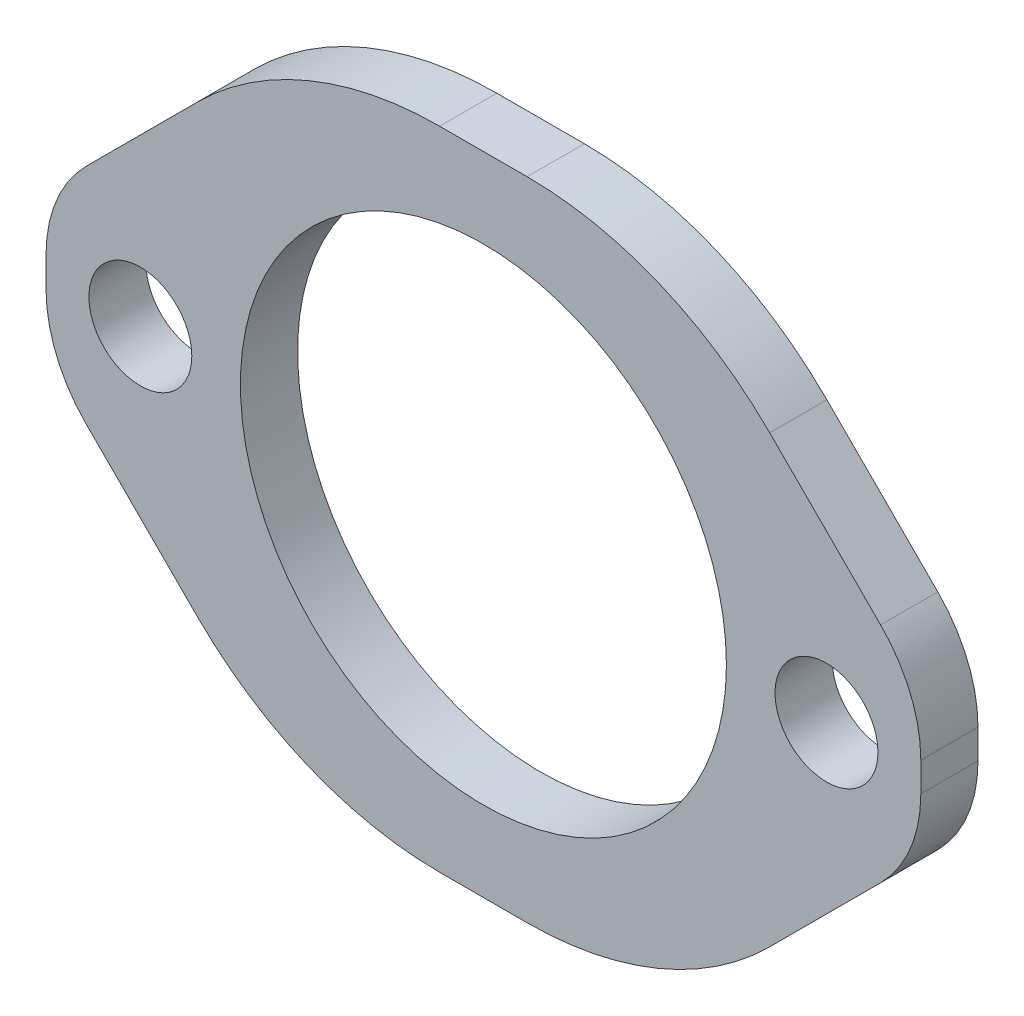
from build123d import *

# Parameters (mm, degrees)
ESQUISSE1_W        = 76.5
ESQUISSE1_H        = 56.5
ESQUISSE1_R        = 21.25
ESQUISSE1_R_2      = 4.5
BOSS_EXTRU_1_DEPTH = 5
CHANFREIN1_SIZE    = 22
CHANFREIN2_SIZE    = 22
CHANFREIN3_SIZE    = 22
CHANFREIN4_SIZE    = 22
CONG_2_R           = 30
CONG_3_R           = 30
CONG_4_R           = 30
CONG_5_R           = 30
CONG_6_R           = 12
CONG_7_R           = 12
CONG_8_R           = 12
CONG_9_R           = 12


with BuildPart() as part:
    # Esquisse1 → Boss.-Extru.1 (new body)
    with BuildSketch(Plane.XY):
        Rectangle(ESQUISSE1_W, ESQUISSE1_H)
        Circle(ESQUISSE1_R, mode=Mode.SUBTRACT)
        with Locations((30, 0)):
            Circle(ESQUISSE1_R_2, mode=Mode.SUBTRACT)
        with Locations((-30, 0)):
            Circle(ESQUISSE1_R_2, mode=Mode.SUBTRACT)
    extrude(amount=BOSS_EXTRU_1_DEPTH)

    # Chanfrein1
    chanfrein1_edges = [part.edges().sort_by_distance(p)[0] for p in [
        (38.25, 28.25, 2.5),
    ]]
    chamfer(chanfrein1_edges, length=CHANFREIN1_SIZE)

    # Chanfrein2
    chanfrein2_edges = [part.edges().sort_by_distance(p)[0] for p in [
        (-38.25, 28.25, 2.5),
    ]]
    chamfer(chanfrein2_edges, length=CHANFREIN2_SIZE)

    # Chanfrein3
    chanfrein3_edges = [part.edges().sort_by_distance(p)[0] for p in [
        (-38.25, -28.25, 2.5),
    ]]
    chamfer(chanfrein3_edges, length=CHANFREIN3_SIZE)

    # Chanfrein4
    chanfrein4_edges = [part.edges().sort_by_distance(p)[0] for p in [
        (38.25, -28.25, 2.5),
    ]]
    chamfer(chanfrein4_edges, length=CHANFREIN4_SIZE)

    # Congé2
    cong_2_edges = [part.edges().sort_by_distance(p)[0] for p in [
        (16.25, 28.25, 2.5),
    ]]
    fillet(cong_2_edges, radius=CONG_2_R)

    # Congé3
    cong_3_edges = [part.edges().sort_by_distance(p)[0] for p in [
        (-16.25, 28.25, 2.5),
    ]]
    fillet(cong_3_edges, radius=CONG_3_R)

    # Congé4
    cong_4_edges = [part.edges().sort_by_distance(p)[0] for p in [
        (16.25, -28.25, 2.5),
    ]]
    fillet(cong_4_edges, radius=CONG_4_R)

    # Congé5
    cong_5_edges = [part.edges().sort_by_distance(p)[0] for p in [
        (-16.25, -28.25, 2.5),
    ]]
    fillet(cong_5_edges, radius=CONG_5_R)

    # Congé6
    cong_6_edges = [part.edges().sort_by_distance(p)[0] for p in [
        (38.25, 6.25, 2.5),
    ]]
    fillet(cong_6_edges, radius=CONG_6_R)

    # Congé7
    cong_7_edges = [part.edges().sort_by_distance(p)[0] for p in [
        (38.25, -6.25, 2.5),
    ]]
    fillet(cong_7_edges, radius=CONG_7_R)

    # Congé8
    cong_8_edges = [part.edges().sort_by_distance(p)[0] for p in [
        (-38.25, 6.25, 2.5),
    ]]
    fillet(cong_8_edges, radius=CONG_8_R)

    # Congé9
    cong_9_edges = [part.edges().sort_by_distance(p)[0] for p in [
        (-38.25, -6.25, 2.5),
    ]]
    fillet(cong_9_edges, radius=CONG_9_R)


solid = part.part
